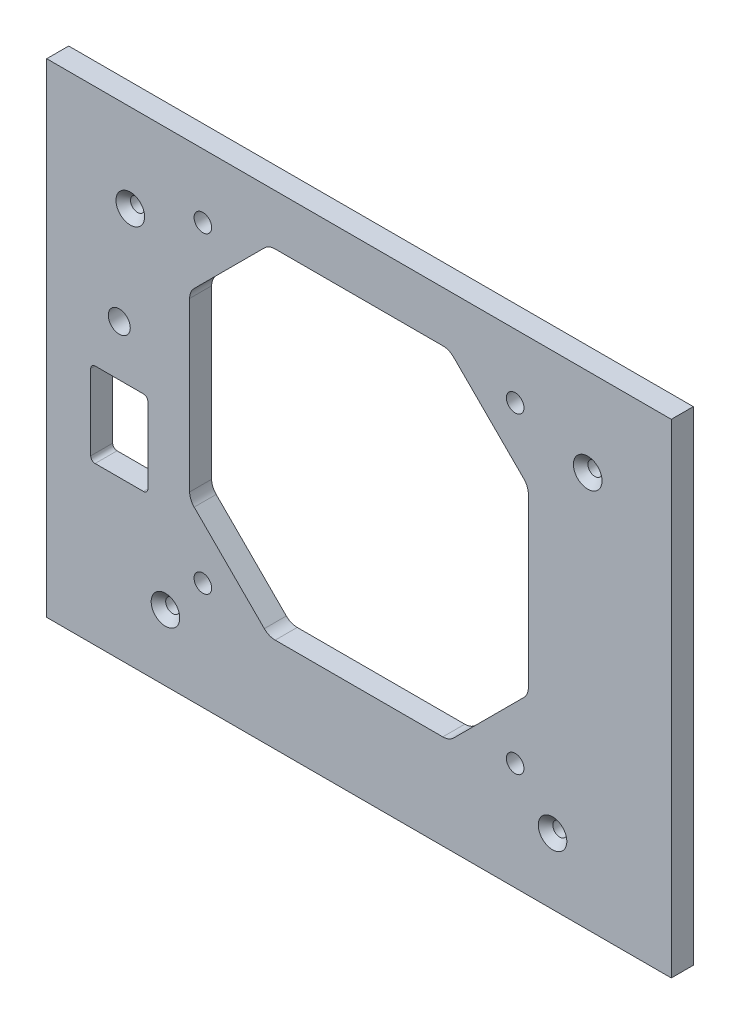
from build123d import *

# Parameters (mm, degrees)
SKETCH1_W                              = 142
SKETCH1_H                              = 110
SHEET_DEPTH                            = 2.5
SKETCH7_R                              = 2
FANHOLES_DEPTH                         = 6
FILLET1_R                              = 3.5
F_3_2_3_2_TOPMOUNTHOLES_D              = 3.2
F_3_2_3_2_TOPMOUNTHOLES_CSINK_D        = 6.5
F_3_2_3_2_TOPMOUNTHOLES_CSINK_ANGLE    = 90
F_3_2_3_2_BOTTOMMOUNTHOLES_D           = 3.2
F_3_2_3_2_BOTTOMMOUNTHOLES_CSINK_D     = 6.5
F_3_2_3_2_BOTTOMMOUNTHOLES_CSINK_ANGLE = 90
SWITCHSLOT_DEPTH                       = 6
SKETCH8_R                              = 2.5
LEDHOLE_DEPTH                          = 6


with BuildPart() as part:
    # Sketch1 → Sheet (new body, symmetric)
    with BuildSketch(Plane.XY):
        Rectangle(SKETCH1_W, SKETCH1_H)
    extrude(amount=SHEET_DEPTH, both=True)

    # Sketch7 → FanHoles (cut, through all)
    with BuildSketch(Plane.XY.offset(2.5)):
        with Locations((-35.5, -30.5)):
            Circle(SKETCH7_R)
        with Locations((35.5, -30.5)):
            Circle(SKETCH7_R)
        with Locations((35.5, 40.5)):
            Circle(SKETCH7_R)
        with Locations((-35.5, 40.5)):
            Circle(SKETCH7_R)
        Polygon((-20.5, 43.5), (-38.5, 25.5), (-38.5, -15.5), (-20.5, -33.5), (20.5, -33.5), (38.5, -15.5), (38.5, 25.5), (20.5, 43.5), align=None)
    extrude(amount=-FANHOLES_DEPTH, mode=Mode.SUBTRACT)

    # Fillet1
    fillet1_edges = [part.edges().sort_by_distance(p)[0] for p in [
        (-20.5, 43.5, 0),
        (20.5, 43.5, 0),
        (38.5, 25.5, 0),
        (38.5, -15.5, 0),
        (20.5, -33.5, 0),
        (-20.5, -33.5, 0),
        (-38.5, -15.5, 0),
        (-38.5, 25.5, 0),
    ]]
    fillet(fillet1_edges, radius=FILLET1_R)

    # Ø3.2 (3.2) TopMountHoles (through all)
    with Locations(Plane.XY.offset(2.5)):
        with Locations((-52, 35), (52, 35)):
            CounterSinkHole(F_3_2_3_2_TOPMOUNTHOLES_D / 2, F_3_2_3_2_TOPMOUNTHOLES_CSINK_D / 2, counter_sink_angle=F_3_2_3_2_TOPMOUNTHOLES_CSINK_ANGLE)

    # Ø3.2 (3.2) BottomMountHoles (through all)
    with Locations(Plane.XY.offset(2.5)):
        with Locations((-44, -40), (44, -40)):
            CounterSinkHole(F_3_2_3_2_BOTTOMMOUNTHOLES_D / 2, F_3_2_3_2_BOTTOMMOUNTHOLES_CSINK_D / 2, counter_sink_angle=F_3_2_3_2_BOTTOMMOUNTHOLES_CSINK_ANGLE)

    # Sketch13 → SwitchSlot (cut, through all)
    with BuildSketch(Plane.XY.offset(2.5)):
        with BuildLine():
            Line((-60, 0), (-49, 0))
            ThreePointArc((-49, 0), (-48.292893219, -0.292893219), (-48, -1))
            Line((-48, -1), (-48, -18.2))
            ThreePointArc((-48, -18.2), (-48.292893219, -18.907106781), (-49, -19.2))
            Line((-49, -19.2), (-60, -19.2))
            ThreePointArc((-60, -19.2), (-60.707106781, -18.907106781), (-61, -18.2))
            Line((-61, -18.2), (-61, -1))
            ThreePointArc((-61, -1), (-60.707106781, -0.292893219), (-60, 0))
        make_face()
    extrude(amount=-SWITCHSLOT_DEPTH, mode=Mode.SUBTRACT)

    # Sketch8 → LEDHole (cut, through all)
    with BuildSketch(Plane.XY.offset(2.5)):
        with Locations((-54.5, 11.5)):
            Circle(SKETCH8_R)
    extrude(amount=-LEDHOLE_DEPTH, mode=Mode.SUBTRACT)


solid = part.part
